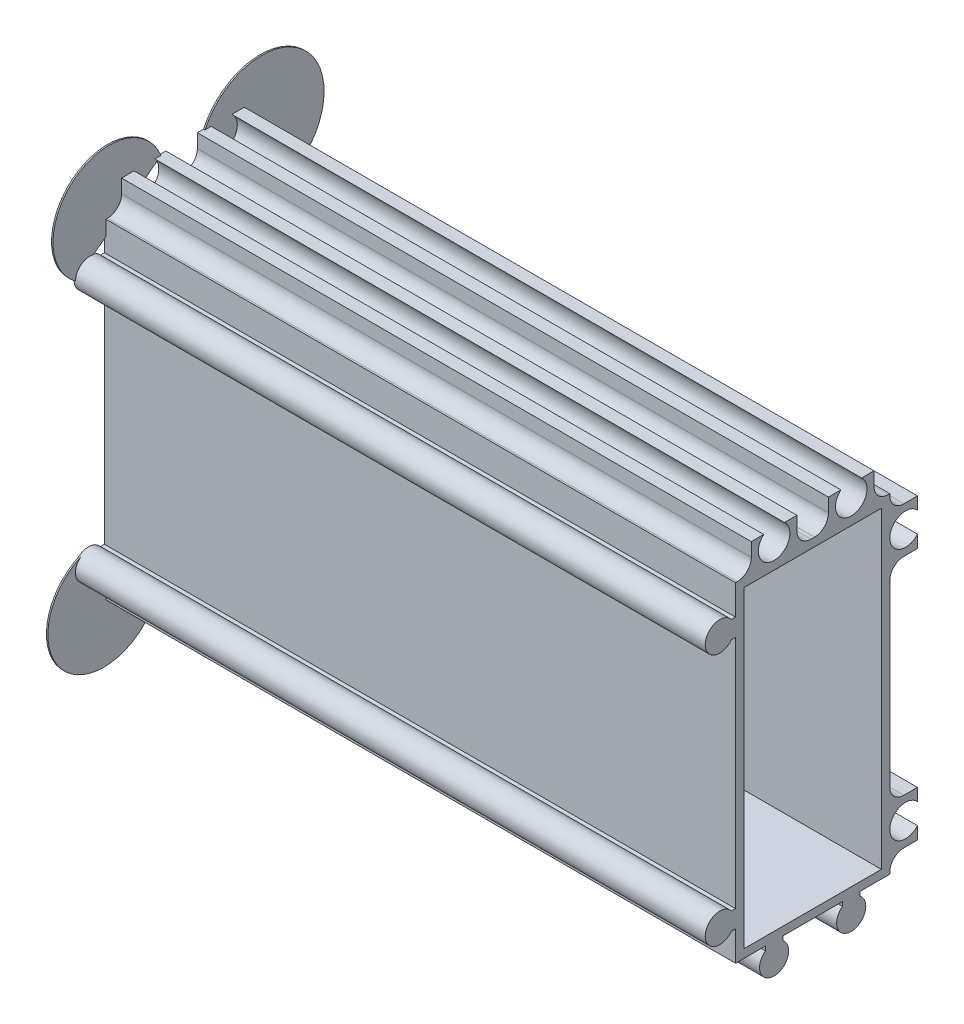
from build123d import *

# Parameters (mm, degrees)
EXTRUDE_1_DEPTH             = 90
SKETCH_2_W                  = 90
SKETCH_2_H                  = 17.75
EXTRUDE_2_DEPTH             = 8.2
SKETCH_3_W                  = 90
SKETCH_3_H                  = 50.95
EXTRUDE_3_DEPTH             = 8.2
SKETCH_4_W                  = 3.95
SKETCH_4_H                  = 29.5
CUT_EXTRUDE_1_DEPTH         = 91
SKETCH_5_W                  = 3.95
SKETCH_5_H                  = 6.2
CUT_EXTRUDE_2_DEPTH         = 91
SKETCH_6_W                  = 2.25
SKETCH_6_H                  = 3.95
CUT_EXTRUDE_3_DEPTH         = 91
SKETCH_7_W                  = 4.5
SKETCH_7_H                  = 3.95
CUT_EXTRUDE_4_DEPTH         = 91
SKETCH_8_W                  = 2.25
SKETCH_8_H                  = 3.95
CUT_EXTRUDE_5_DEPTH         = 91
SKETCH_9_W                  = 3.95
SKETCH_9_H                  = 2.25
CUT_EXTRUDE_6_DEPTH         = 91
SKETCH_10_W                 = 19.6
SKETCH_10_H                 = 44.6
CUT_EXTRUDE_7_DEPTH         = 86.2
HOLE_WIZARD_2_5_2_5_1_D     = 2.5
HOLE_WIZARD_2_5_2_5_1_DEPTH = 90
HOLE_WIZARD_4_5_4_5_1_D     = 4.5
HOLE_WIZARD_4_5_4_5_1_DEPTH = 90
FILLET_1_R                  = 2
FILLET_2_R                  = 2
SKETCH_17_R                 = 1.25
EXTRUDE_4_DEPTH             = 90
EXTRUDE_5_DEPTH             = 0.2


with BuildPart() as part:
    # Эскиз1 → Бобышка-Вытянуть1 (new body)
    with BuildSketch(Plane(origin=(90, 0, 0), x_dir=(0, 0, -1), z_dir=(1, 0, 0))):
        with BuildLine():
            Line((6.75, -24.093761792), (6.75, 19.25))
            Line((6.75, 19.25), (-11.593761792, 19.25))
            ThreePointArc((-11.593761792, 19.25), (-15.325, 18), (-11.593761792, 16.75))
            Line((-11.593761792, 16.75), (-11, 16.75))
            Line((-11, 16.75), (-11, -16.75))
            Line((-11, -16.75), (-11.593761792, -16.75))
            ThreePointArc((-11.593761792, -16.75), (-15.325, -18), (-11.593761792, -19.25))
            Line((-11.593761792, -19.25), (-11, -19.25))
            Line((-11, -19.25), (-11, -23.5))
            Line((-11, -23.5), (-6.75, -23.5))
            Line((-6.75, -23.5), (-6.75, -24.093761792))
            ThreePointArc((-6.75, -24.093761792), (-5.5, -27.825), (-4.25, -24.093761792))
            Line((-4.25, -24.093761792), (-4.25, -23.5))
            Line((-4.25, -23.5), (4.25, -23.5))
            Line((4.25, -23.5), (4.25, -24.093761792))
            ThreePointArc((4.25, -24.093761792), (5.5, -27.825), (6.75, -24.093761792))
        make_face()
    extrude(amount=-EXTRUDE_1_DEPTH)

    # Эскиз2 → Бобышка-Вытянуть2 (add)
    with BuildSketch(Plane(origin=(0, 19.25, 0), x_dir=(-1, 0, 0), z_dir=(0, 1, 0))):
        with Locations((-45, 2.125)):
            Rectangle(SKETCH_2_W, SKETCH_2_H)
    extrude(amount=EXTRUDE_2_DEPTH)

    # Эскиз3 → Бобышка-Вытянуть3 (add)
    with BuildSketch(Plane(origin=(0, 0, -6.75), x_dir=(-1, 0, 0), z_dir=(0, 0, -1))):
        with Locations((-45, 1.975)):
            Rectangle(SKETCH_3_W, SKETCH_3_H)
    extrude(amount=EXTRUDE_3_DEPTH)

    # Эскиз4 → Вырез-Вытянуть1 (cut, through all)
    with BuildSketch(Plane.ZY):
        with Locations((-12.975, 0)):
            Rectangle(SKETCH_4_W, SKETCH_4_H)
    extrude(amount=-CUT_EXTRUDE_1_DEPTH, mode=Mode.SUBTRACT)

    # Эскиз5 → Вырез-Вытянуть2 (cut, through all)
    with BuildSketch(Plane.ZY):
        with Locations((-12.975, 24.35)):
            Rectangle(SKETCH_5_W, SKETCH_5_H)
    extrude(amount=-CUT_EXTRUDE_2_DEPTH, mode=Mode.SUBTRACT)

    # Эскиз6 → Вырез-Вытянуть3 (cut, through all)
    with BuildSketch(Plane.ZY):
        with Locations((-9.875, 25.475)):
            Rectangle(SKETCH_6_W, SKETCH_6_H)
    extrude(amount=-CUT_EXTRUDE_3_DEPTH, mode=Mode.SUBTRACT)

    # Эскиз7 → Вырез-Вытянуть4 (cut, through all)
    with BuildSketch(Plane.ZY):
        with Locations((0, 25.475)):
            Rectangle(SKETCH_7_W, SKETCH_7_H)
    extrude(amount=-CUT_EXTRUDE_4_DEPTH, mode=Mode.SUBTRACT)

    # Эскиз8 → Вырез-Вытянуть5 (cut, through all)
    with BuildSketch(Plane.ZY):
        with Locations((9.875, 25.475)):
            Rectangle(SKETCH_8_W, SKETCH_8_H)
    extrude(amount=-CUT_EXTRUDE_5_DEPTH, mode=Mode.SUBTRACT)

    # Эскиз9 → Вырез-Вытянуть6 (cut, through all)
    with BuildSketch(Plane.ZY):
        with Locations((-12.975, -22.375)):
            Rectangle(SKETCH_9_W, SKETCH_9_H)
    extrude(amount=-CUT_EXTRUDE_6_DEPTH, mode=Mode.SUBTRACT)

    # Эскиз10 → Вырез-Вытянуть7 (cut)
    with BuildSketch(Plane(origin=(90, 0, 0), x_dir=(0, 0, -1), z_dir=(1, 0, 0))):
        Rectangle(SKETCH_10_W, SKETCH_10_H)
    extrude(amount=-CUT_EXTRUDE_7_DEPTH, mode=Mode.SUBTRACT)

    # Диаметр отверстия Ø2.5 (2.5)1
    with Locations(Plane(origin=(90, 0, 0), x_dir=(0, 0, -1), z_dir=(1, 0, 0))):
        with Locations((5.5, -25.75), (-13.25, -18), (-5.5, -25.75), (-13.25, 18)):
            Hole(HOLE_WIZARD_2_5_2_5_1_D / 2, depth=HOLE_WIZARD_2_5_2_5_1_DEPTH)

    # Диаметр отверстия Ø4.5 (4.5)1
    with Locations(Plane.ZY):
        with Locations((-13.25, -18), (-13.25, 18), (-5.5, 25.75), (5.5, 25.75)):
            Hole(HOLE_WIZARD_4_5_4_5_1_D / 2, depth=HOLE_WIZARD_4_5_4_5_1_DEPTH)

    # Скругление1
    fillet_1_edges = [part.edges().sort_by_distance(p)[0] for p in [
        (45, 23.5, 8.75),
    ]]
    fillet(fillet_1_edges, radius=FILLET_1_R)

    # Скругление2
    fillet_2_edges = [part.edges().sort_by_distance(p)[0] for p in [
        (45, 23.5, -8.75),
        (45, 23.5, 2.25),
        (45, 23.5, -2.25),
        (45, -21.25, -11),
        (45, 14.75, -11),
        (45, -14.75, -11),
        (45, 21.25, -11),
    ]]
    fillet(fillet_2_edges, radius=FILLET_2_R)

    # Эскиз17 → Бобышка-Вытянуть4 (add)
    with BuildSketch(Plane(origin=(90, 0, 0), x_dir=(0, 0, -1), z_dir=(1, 0, 0))):
        with Locations((5.5, -25.75)):
            Circle(SKETCH_17_R)
        with Locations((-5.5, -25.75)):
            Circle(SKETCH_17_R)
        with Locations((-13.25, -18)):
            Circle(SKETCH_17_R)
        with Locations((-13.25, 18)):
            Circle(SKETCH_17_R)
    extrude(amount=-EXTRUDE_4_DEPTH)

    # Эскиз19 → Бобышка-Вытянуть5 (add)
    with BuildSketch(Plane.ZY):
        with BuildLine():
            Line((-14.95, 15.638029851), (-3.138029851, 27.45))
            ThreePointArc((-3.138029851, 27.45), (-17.517080976, 30.017080976), (-14.95, 15.638029851))
        make_face()
        with BuildLine():
            Line((15.325, 18), (3.138029851, 27.45))
            ThreePointArc((3.138029851, 27.45), (15.439952139, 30.731564972), (15.325, 18))
        make_face()
        with BuildLine():
            Line((14.608219689, -16.431285789), (4.121265041, -27.300714324))
            ThreePointArc((4.121265041, -27.300714324), (17.021902806, -29.253720028), (14.608219689, -16.431285789))
        make_face()
        with BuildLine():
            Line((-5.5, -27.825), (-14.95, -15.638029851))
            ThreePointArc((-14.95, -15.638029851), (-18.231564972, -27.939952139), (-5.5, -27.825))
        make_face()
    extrude(amount=-EXTRUDE_5_DEPTH)


solid = part.part
